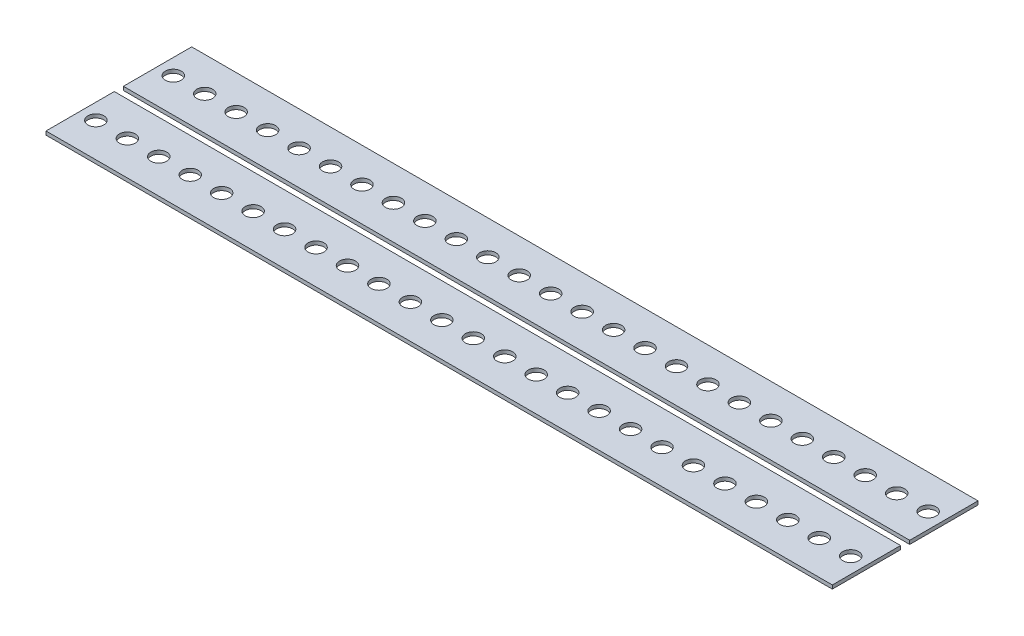
from build123d import *

# Parameters (mm, degrees)
SKETCH1_W           = 6.90897887
SKETCH1_H           = 15
SKETCH1_R           = 1.75
BOSS_EXTRUDE1_DEPTH = 0.8
LPATTERN1_COUNT     = 25
LPATTERN1_PITCH     = 6.90897887
LPATTERN2_COUNT     = 2
LPATTERN2_PITCH     = 17


with BuildPart() as part:
    # Sketch1 → Boss-Extrude1 (new body)
    with BuildSketch(Plane(origin=(0, 0, 0), x_dir=(1, 0, 0), z_dir=(0, 1, 0))):
        Rectangle(SKETCH1_W, SKETCH1_H)
        Circle(SKETCH1_R, mode=Mode.SUBTRACT)
    boss_extrude1 = extrude(amount=BOSS_EXTRUDE1_DEPTH)

    # LPattern1: Boss-Extrude1 ×25
    with Locations(*[(-i * LPATTERN1_PITCH, 0, 0) for i in range(1, LPATTERN1_COUNT)]):
        add(boss_extrude1)


with BuildPart() as lpattern2_1:
    # LPattern2: pattern copy
    add(part.part.moved(Location(Vector(0, 0, -1) * (1 * LPATTERN2_PITCH))))


solid = Compound([part.part, lpattern2_1.part])
